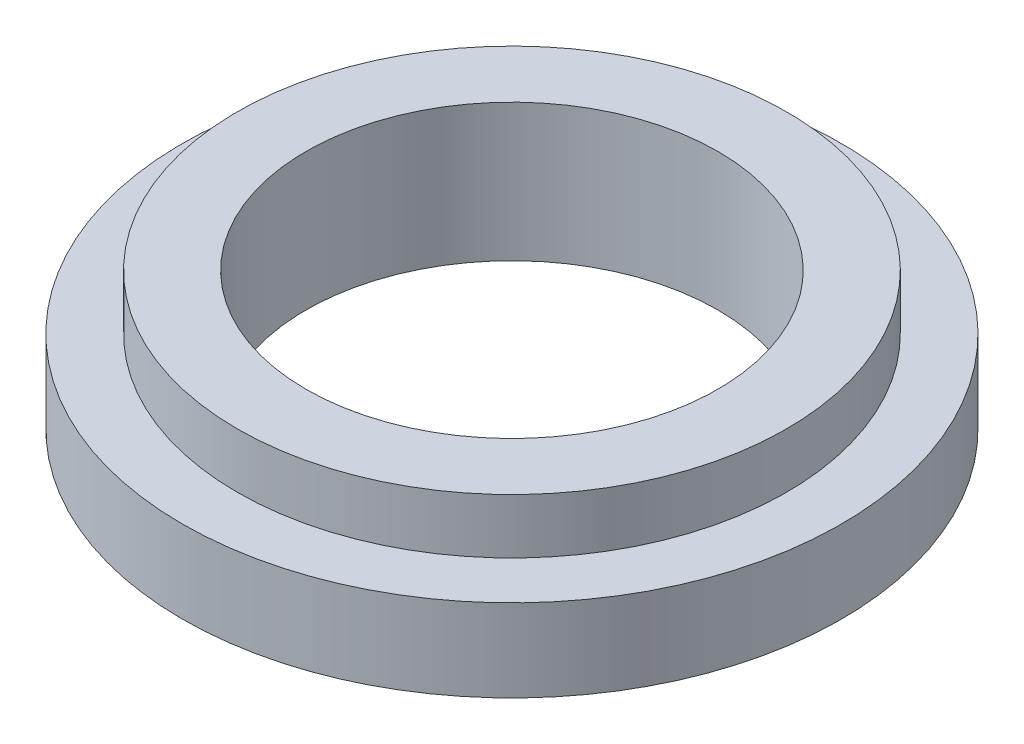
from build123d import *

# Parameters (mm, degrees)
SKETCH1_R           = 12
SKETCH1_R_2         = 7.5
BOSS_EXTRUDE1_DEPTH = 3
SKETCH2_R           = 1
CUT_EXTRUDE1_DEPTH  = 2.2
SKETCH3_R           = 10
SKETCH3_R_2         = 7.5
BOSS_EXTRUDE2_DEPTH = 2


with BuildPart() as part:
    # Sketch1 → Boss-Extrude1 (new body)
    with BuildSketch(Plane(origin=(0, 0, 0), x_dir=(1, 0, 0), z_dir=(0, 1, 0))):
        Circle(SKETCH1_R)
        Circle(SKETCH1_R_2, mode=Mode.SUBTRACT)
    extrude(amount=BOSS_EXTRUDE1_DEPTH)

    # Sketch2 → Cut-Extrude1 (cut)
    with BuildSketch(Plane.XZ):
        with Locations((0, 10)):
            Circle(SKETCH2_R)
        with Locations((-8.660254038, 5)):
            Circle(SKETCH2_R)
        with Locations((-8.660254038, -5)):
            Circle(SKETCH2_R)
        with Locations((0, -10)):
            Circle(SKETCH2_R)
        with Locations((8.660254038, -5)):
            Circle(SKETCH2_R)
        with Locations((8.660254038, 5)):
            Circle(SKETCH2_R)
    extrude(amount=-CUT_EXTRUDE1_DEPTH, mode=Mode.SUBTRACT)

    # Sketch3 → Boss-Extrude2 (add)
    with BuildSketch(Plane(origin=(0, 3, 0), x_dir=(1, 0, 0), z_dir=(0, 1, 0))):
        Circle(SKETCH3_R)
        Circle(SKETCH3_R_2, mode=Mode.SUBTRACT)
    extrude(amount=BOSS_EXTRUDE2_DEPTH)


solid = part.part
